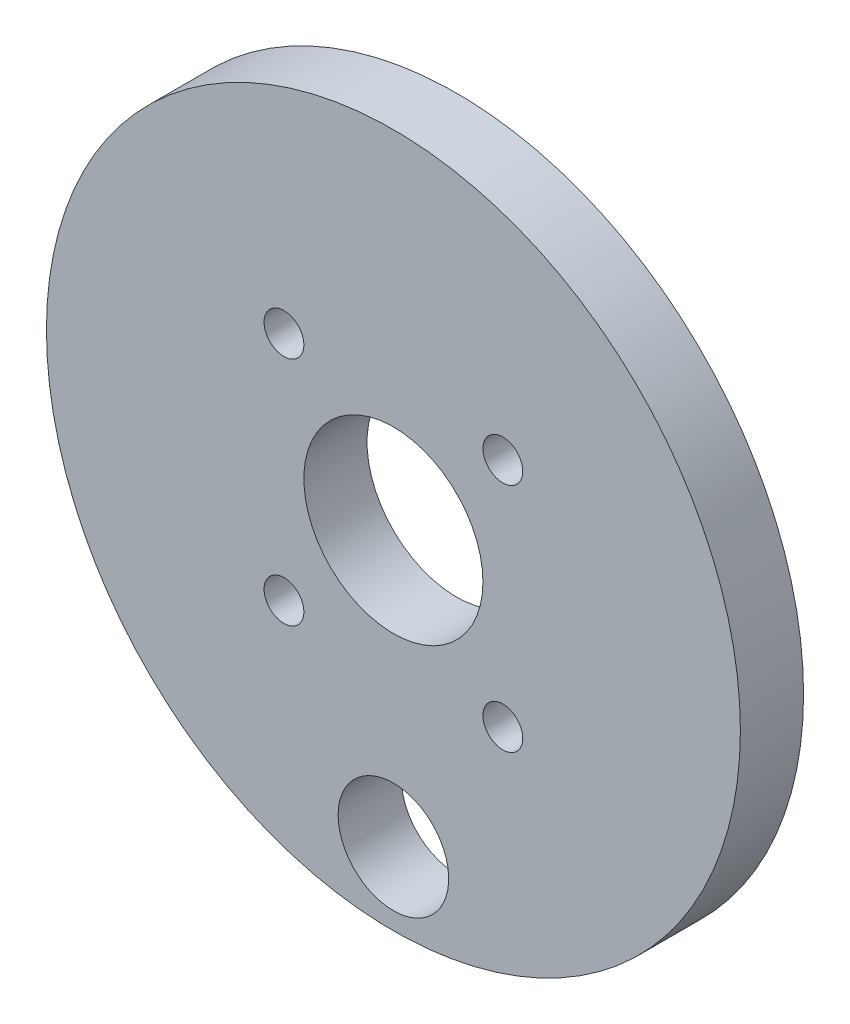
from build123d import *

# Parameters (mm, degrees)
SKETCH1_R           = 34.875
SKETCH1_R_2         = 9
BOSS_EXTRUDE1_DEPTH = 6.35
SKETCH2_R           = 2
CUT_EXTRUDE1_DEPTH  = 7.35
SKETCH3_R           = 5.55625
CUT_EXTRUDE2_DEPTH  = 7.35


with BuildPart() as part:
    # Sketch1 → Boss-Extrude1 (new body)
    with BuildSketch(Plane.XY):
        Circle(SKETCH1_R)
        Circle(SKETCH1_R_2, mode=Mode.SUBTRACT)
    extrude(amount=BOSS_EXTRUDE1_DEPTH)

    # Sketch2 → Cut-Extrude1 (cut, through all)
    with BuildSketch(Plane(origin=(0, 0, 0), x_dir=(-1, 0, 0), z_dir=(0, 0, -1))):
        with Locations((-11, 11.618950039)):
            Circle(SKETCH2_R)
        with Locations((11, 11.618950039)):
            Circle(SKETCH2_R)
        with Locations((11, -11.618950039)):
            Circle(SKETCH2_R)
        with Locations((-11, -11.618950039)):
            Circle(SKETCH2_R)
    extrude(amount=-CUT_EXTRUDE1_DEPTH, mode=Mode.SUBTRACT)

    # Sketch3 → Cut-Extrude2 (cut, through all)
    with BuildSketch(Plane(origin=(0, 0, 0), x_dir=(-1, 0, 0), z_dir=(0, 0, -1))):
        with Locations((0, -27.559440888)):
            Circle(SKETCH3_R)
    extrude(amount=-CUT_EXTRUDE2_DEPTH, mode=Mode.SUBTRACT)


solid = part.part
